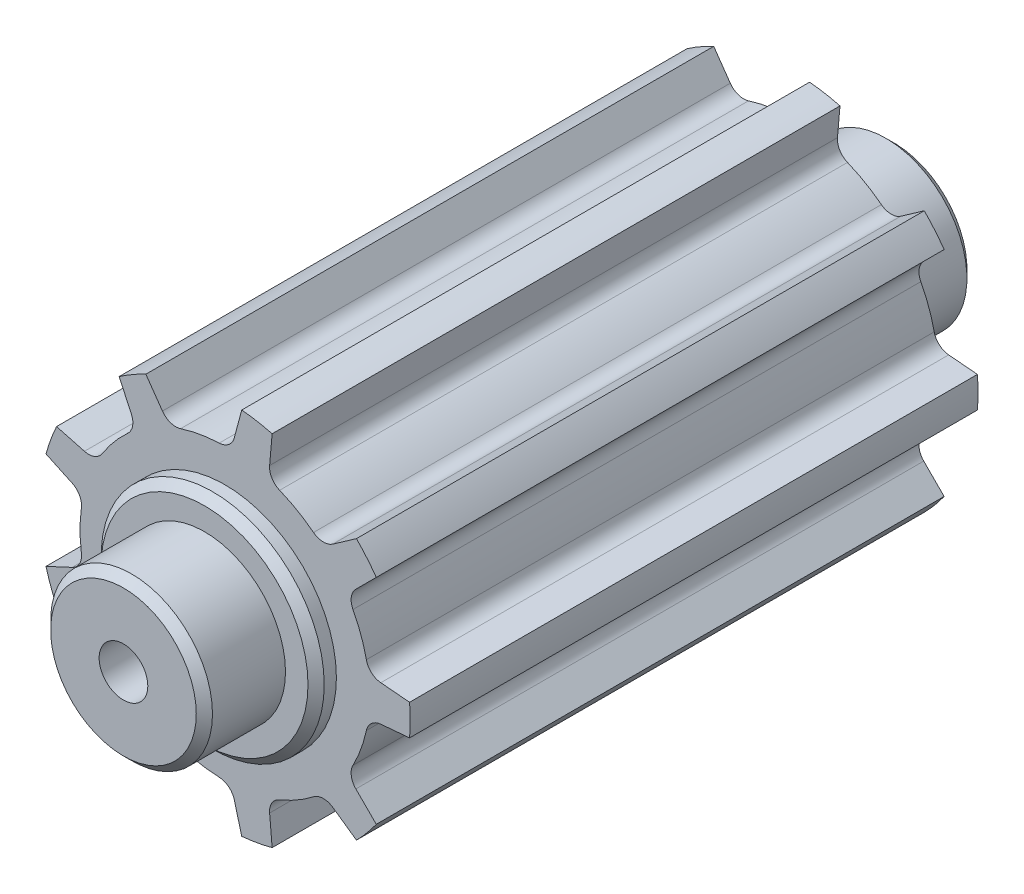
from build123d import *

# Parameters (mm, degrees)
SKETCH2_R           = 2
BOSS_EXTRUDE1_DEPTH = 14
SKETCH3_R           = 2.75
BOSS_EXTRUDE2_DEPTH = 14.5
SKETCH4_R           = 2.75
BOSS_EXTRUDE3_DEPTH = 0.5
SKETCH5_R           = 1.995
BOSS_EXTRUDE4_DEPTH = 2
SKETCH6_R           = 1.995
BOSS_EXTRUDE5_DEPTH = 2
SKETCH7_R           = 0.6
CUT_EXTRUDE1_DEPTH  = 21
CHAMFER1_SIZE       = 0.2


with BuildPart() as part:
    # Sketch2 → Boss-Extrude1 (new body)
    with BuildSketch(Plane.XY):
        with BuildLine():
            Line((-4.409637173, -1.2), (-3.764514138, -0.899174188))
            ThreePointArc((-3.764514138, -0.899174188), (-3.582420347, -0.728223333), (-3.537232834, -0.482580436))
            ThreePointArc((-3.537232834, -0.482580436), (-3.57, 0), (-3.537232834, 0.482580436))
            ThreePointArc((-3.537232834, 0.482580436), (-3.582420347, 0.728223333), (-3.764514138, 0.899174188))
            Line((-3.764514138, 0.899174188), (-4.409637173, 1.2))
            ThreePointArc((-4.409637173, 1.2), (-4.294395277, 1.563032055), (-4.149323184, 1.915206806))
            Line((-4.149323184, 1.915206806), (-3.461763164, 1.730975654))
            ThreePointArc((-3.461763164, 1.730975654), (-3.212386135, 1.744883974), (-3.019874282, 1.904011377))
            ThreePointArc((-3.019874282, 1.904011377), (-2.734778662, 2.294751767), (-2.399480831, 2.6433675))
            ThreePointArc((-2.399480831, 2.6433675), (-2.276200264, 2.860586849), (-2.305807109, 3.108590435))
            Line((-2.305807109, 3.108590435), (-2.606632921, 3.75371347))
            ThreePointArc((-2.606632921, 3.75371347), (-2.285, 3.957736095), (-1.947494763, 4.134267063))
            Line((-1.947494763, 4.134267063), (-1.539214732, 3.55118275))
            ThreePointArc((-1.539214732, 3.55118275), (-1.339240749, 3.401540677), (-1.089482991, 3.399695106))
            ThreePointArc((-1.089482991, 3.399695106), (-0.619923994, 3.515763678), (-0.13898508, 3.567293533))
            ThreePointArc((-0.13898508, 3.567293533), (0.095079219, 3.654449987), (0.231812692, 3.863462669))
            Line((0.231812692, 3.863462669), (0.416043844, 4.551022689))
            ThreePointArc((0.416043844, 4.551022689), (0.793572172, 4.500571431), (1.165588102, 4.418857814))
            Line((1.165588102, 4.418857814), (1.10354938, 3.709751971))
            ThreePointArc((1.10354938, 3.709751971), (1.160550267, 3.466578694), (1.3506895, 3.304623712))
            ThreePointArc((1.3506895, 3.304623712), (1.785, 3.091710692), (2.186543334, 2.822043275))
            ThreePointArc((2.186543334, 2.822043275), (2.421870079, 2.738355361), (2.660964759, 2.810577782))
            Line((2.660964759, 2.810577782), (3.244049071, 3.218857814))
            ThreePointArc((3.244049071, 3.218857814), (3.500823105, 2.937539376), (3.73327934, 2.635815883))
            Line((3.73327934, 2.635815883), (3.229950472, 2.132487015))
            ThreePointArc((3.229950472, 2.132487015), (3.117306916, 1.909566013), (3.158859362, 1.663282156))
            ThreePointArc((3.158859362, 1.663282156), (3.354702656, 1.221011912), (3.488963822, 0.756327606))
            ThreePointArc((3.488963822, 0.756327606), (3.615441013, 0.540953828), (3.845021841, 0.442592316))
            Line((3.845021841, 0.442592316), (4.554127684, 0.380553593))
            ThreePointArc((4.554127684, 0.380553593), (4.57, 0), (4.554127684, -0.380553593))
            Line((4.554127684, -0.380553593), (3.845021841, -0.442592316))
            ThreePointArc((3.845021841, -0.442592316), (3.615441013, -0.540953828), (3.488963822, -0.756327606))
            ThreePointArc((3.488963822, -0.756327606), (3.354702656, -1.221011912), (3.158859362, -1.663282156))
            ThreePointArc((3.158859362, -1.663282156), (3.117306916, -1.909566013), (3.229950472, -2.132487015))
            Line((3.229950472, -2.132487015), (3.73327934, -2.635815883))
            ThreePointArc((3.73327934, -2.635815883), (3.500823105, -2.937539376), (3.244049071, -3.218857814))
            Line((3.244049071, -3.218857814), (2.660964759, -2.810577782))
            ThreePointArc((2.660964759, -2.810577782), (2.421870079, -2.738355361), (2.186543334, -2.822043275))
            ThreePointArc((2.186543334, -2.822043275), (1.785, -3.091710692), (1.3506895, -3.304623712))
            ThreePointArc((1.3506895, -3.304623712), (1.160550267, -3.466578694), (1.10354938, -3.709751971))
            Line((1.10354938, -3.709751971), (1.165588102, -4.418857814))
            ThreePointArc((1.165588102, -4.418857814), (0.793572172, -4.500571431), (0.416043844, -4.551022689))
            Line((0.416043844, -4.551022689), (0.231812692, -3.863462669))
            ThreePointArc((0.231812692, -3.863462669), (0.095079219, -3.654449987), (-0.13898508, -3.567293533))
            ThreePointArc((-0.13898508, -3.567293533), (-0.619923994, -3.515763678), (-1.089482991, -3.399695106))
            ThreePointArc((-1.089482991, -3.399695106), (-1.339240749, -3.401540677), (-1.539214732, -3.55118275))
            Line((-1.539214732, -3.55118275), (-1.947494763, -4.134267063))
            ThreePointArc((-1.947494763, -4.134267063), (-2.285, -3.957736095), (-2.606632921, -3.75371347))
            Line((-2.606632921, -3.75371347), (-2.305807109, -3.108590435))
            ThreePointArc((-2.305807109, -3.108590435), (-2.276200264, -2.860586849), (-2.399480831, -2.6433675))
            ThreePointArc((-2.399480831, -2.6433675), (-2.734778662, -2.294751767), (-3.019874282, -1.904011377))
            ThreePointArc((-3.019874282, -1.904011377), (-3.212386135, -1.744883974), (-3.461763164, -1.730975654))
            Line((-3.461763164, -1.730975654), (-4.149323184, -1.915206806))
            ThreePointArc((-4.149323184, -1.915206806), (-4.294395277, -1.563032055), (-4.409637173, -1.2))
        make_face()
        Circle(SKETCH2_R, mode=Mode.SUBTRACT)
    extrude(amount=BOSS_EXTRUDE1_DEPTH)

    # Sketch3 → Boss-Extrude2 (add)
    with BuildSketch(Plane.XY.offset(14)):
        Circle(SKETCH3_R)
    extrude(amount=-BOSS_EXTRUDE2_DEPTH)

    # Sketch4 → Boss-Extrude3 (add)
    with BuildSketch(Plane.XY.offset(14)):
        Circle(SKETCH4_R)
    extrude(amount=BOSS_EXTRUDE3_DEPTH)

    # Sketch5 → Boss-Extrude4 (add)
    with BuildSketch(Plane.XY.offset(14.5)):
        Circle(SKETCH5_R)
    extrude(amount=BOSS_EXTRUDE4_DEPTH)

    # Sketch6 → Boss-Extrude5 (add)
    with BuildSketch(Plane(origin=(0, 0, -0.5), x_dir=(-1, 0, 0), z_dir=(0, 0, -1))):
        Circle(SKETCH6_R)
    extrude(amount=BOSS_EXTRUDE5_DEPTH)

    # Sketch7 → Cut-Extrude1 (cut)
    with BuildSketch(Plane(origin=(0, 0, -2.5), x_dir=(-1, 0, 0), z_dir=(0, 0, -1))):
        Circle(SKETCH7_R)
    extrude(amount=-CUT_EXTRUDE1_DEPTH, mode=Mode.SUBTRACT)

    # Chamfer1
    chamfer1_edges = [part.edges().sort_by_distance(p)[0] for p in [
        (-2.75, 0, -0.5),
        (-2.75, 0, 14.5),
        (-1.995, 0, 16.5),
        (1.995, 0, -2.5),
    ]]
    chamfer(chamfer1_edges, length=CHAMFER1_SIZE)


solid = part.part
